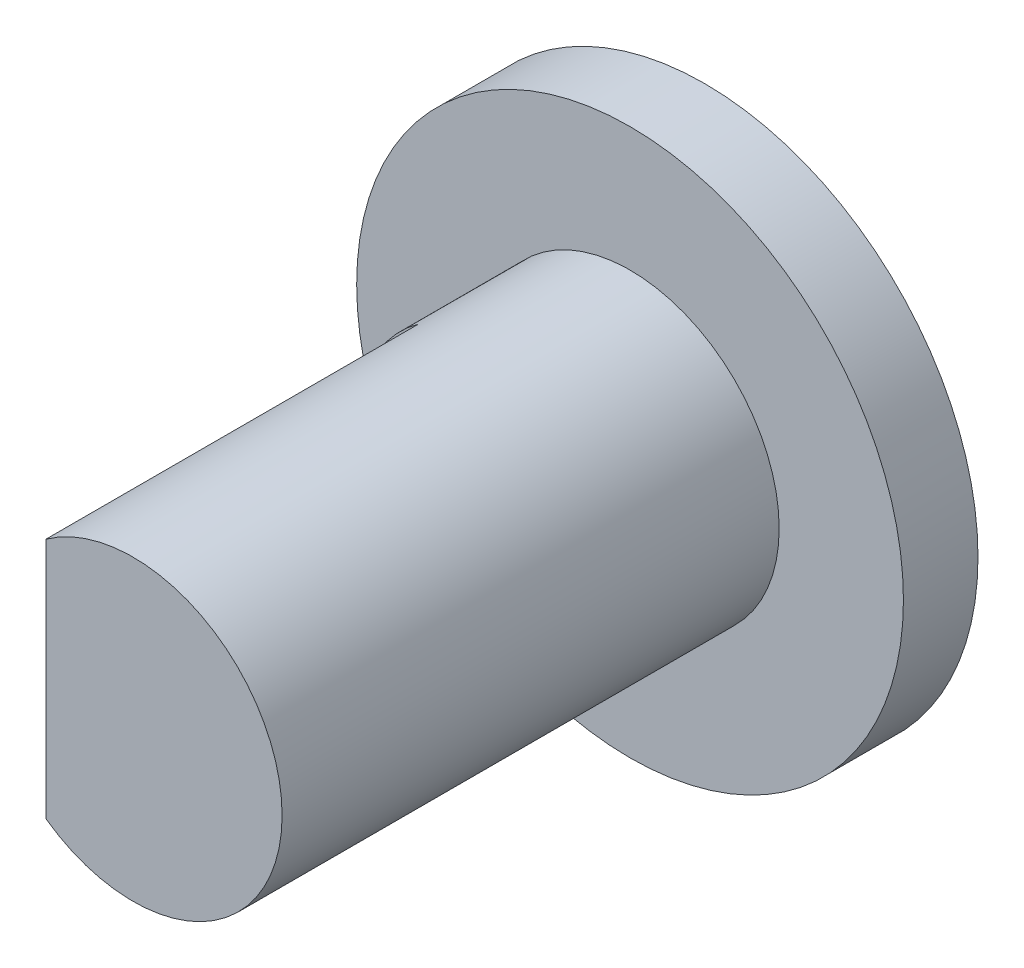
from build123d import *

# Parameters (mm, degrees)
SKETCH1_R           = 11
BOSS_EXTRUDE1_DEPTH = 3
SKETCH2_R           = 6
BOSS_EXTRUDE2_DEPTH = 20
CUT_EXTRUDE1_DEPTH  = 15


with BuildPart() as part:
    # Sketch1 → Boss-Extrude1 (new body)
    with BuildSketch(Plane.XY):
        Circle(SKETCH1_R)
    extrude(amount=BOSS_EXTRUDE1_DEPTH)

    # Sketch2 → Boss-Extrude2 (add)
    with BuildSketch(Plane.XY.offset(3)):
        Circle(SKETCH2_R)
    extrude(amount=BOSS_EXTRUDE2_DEPTH)

    # Sketch3 → Cut-Extrude1 (cut)
    with BuildSketch(Plane.XY.offset(23)):
        with BuildLine():
            Line((-3.5, 4.873397172), (-3.5, -4.873397172))
            ThreePointArc((-3.5, -4.873397172), (-6, 0), (-3.5, 4.873397172))
        make_face()
    extrude(amount=-CUT_EXTRUDE1_DEPTH, mode=Mode.SUBTRACT)


solid = part.part
